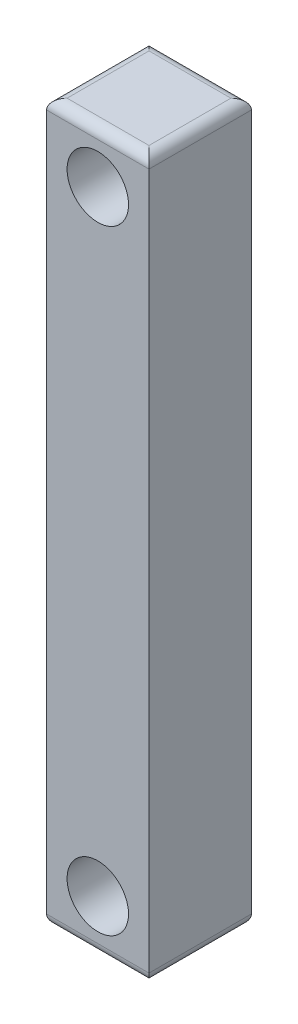
from build123d import *

# Parameters (mm, degrees)
SKETCH1_W          = 25.4
SKETCH1_H          = 177.8
BASE_EXTRUDE_DEPTH = 25.4
SKETCH2_R          = 7.62
CUT_EXTRUDE1_DEPTH = 78.74
FILLET1_R          = 2.54


with BuildPart() as part:
    # Sketch1 → Base-Extrude (new body)
    with BuildSketch(Plane.XY):
        with Locations((-7.849662618, -19.144264507)):
            Rectangle(SKETCH1_W, SKETCH1_H)
    extrude(amount=BASE_EXTRUDE_DEPTH)

    # Sketch2 → Cut-Extrude1 (cut)
    with BuildSketch(Plane.XY.offset(25.4)):
        with Locations((-7.849662618, -95.344264507)):
            Circle(SKETCH2_R)
        with Locations((-7.849662618, 57.055735493)):
            Circle(SKETCH2_R)
    extrude(amount=-CUT_EXTRUDE1_DEPTH, mode=Mode.SUBTRACT)

    # Fillet1
    fillet1_edges = [part.edges().sort_by_distance(p)[0] for p in [
        (-20.549662618, 69.755735493, 12.7),
        (4.850337382, 69.755735493, 12.7),
        (-7.849662618, 69.755735493, 0),
        (-7.849662618, 69.755735493, 25.4),
        (-20.549662618, -108.044264507, 12.7),
        (4.850337382, -108.044264507, 12.7),
        (-7.849662618, -108.044264507, 0),
        (-7.849662618, -108.044264507, 25.4),
    ]]
    fillet(fillet1_edges, radius=FILLET1_R)


solid = part.part
